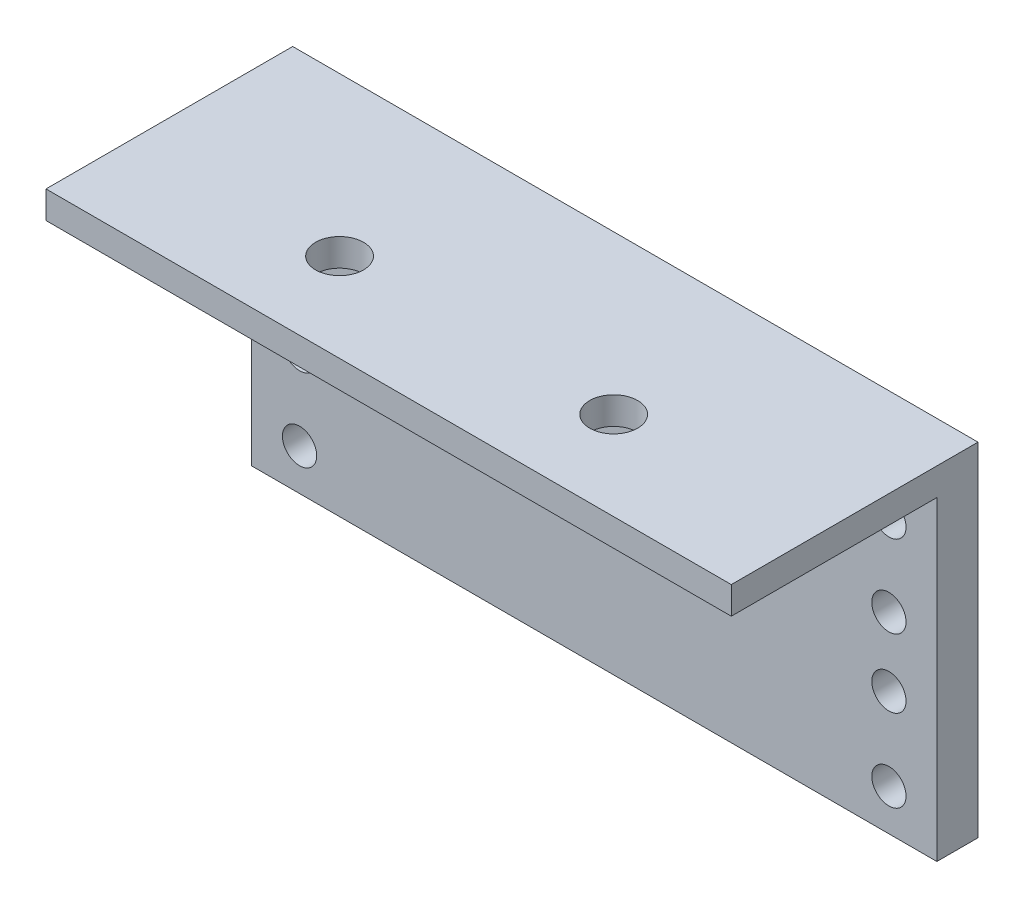
from build123d import *

# Parameters (mm, degrees)
SKETCH1_W           = 50
SKETCH1_H           = 25
BOSS_EXTRUDE1_DEPTH = 3
SKETCH3_W           = 50
SKETCH3_H           = 2
BOSS_EXTRUDE2_DEPTH = 15
SKETCH5_R           = 1.25
CUT_EXTRUDE1_DEPTH  = 15
SKETCH6_R           = 1.75
CUT_EXTRUDE2_DEPTH  = 15


with BuildPart() as part:
    # Sketch1 → Boss-Extrude1 (new body)
    with BuildSketch(Plane.XY):
        with Locations((-25, 12.5)):
            Rectangle(SKETCH1_W, SKETCH1_H)
    extrude(amount=BOSS_EXTRUDE1_DEPTH)

    # Sketch3 → Boss-Extrude2 (add)
    with BuildSketch(Plane.XY.offset(3)):
        with Locations((-25, 24)):
            Rectangle(SKETCH3_W, SKETCH3_H)
    extrude(amount=BOSS_EXTRUDE2_DEPTH)

    # Sketch5 → Cut-Extrude1 (cut)
    with BuildSketch(Plane.XY.offset(3)):
        with Locations((-46.500140762, 20.00924034)):
            Circle(SKETCH5_R)
        with Locations((-46.500140762, 3.00924034)):
            Circle(SKETCH5_R)
        with Locations((-3.500140762, 20.00924034)):
            Circle(SKETCH5_R)
        with Locations((-3.500140762, 3.00924034)):
            Circle(SKETCH5_R)
        with Locations((-3.500140762, 14.00924034)):
            Circle(SKETCH5_R)
        with Locations((-46.500140762, 14.00924034)):
            Circle(SKETCH5_R)
        with Locations((-3.500140762, 9.00924034)):
            Circle(SKETCH5_R)
        with Locations((-46.500140762, 9.00924034)):
            Circle(SKETCH5_R)
    extrude(amount=-CUT_EXTRUDE1_DEPTH, mode=Mode.SUBTRACT)

    # Sketch6 → Cut-Extrude2 (cut)
    with BuildSketch(Plane(origin=(0, 25, 0), x_dir=(1, 0, 0), z_dir=(0, 1, 0))):
        with Locations((-35.046148944, -11.535217426)):
            Circle(SKETCH6_R)
        with Locations((-15.046148944, -11.535217426)):
            Circle(SKETCH6_R)
    extrude(amount=-CUT_EXTRUDE2_DEPTH, mode=Mode.SUBTRACT)


solid = part.part
